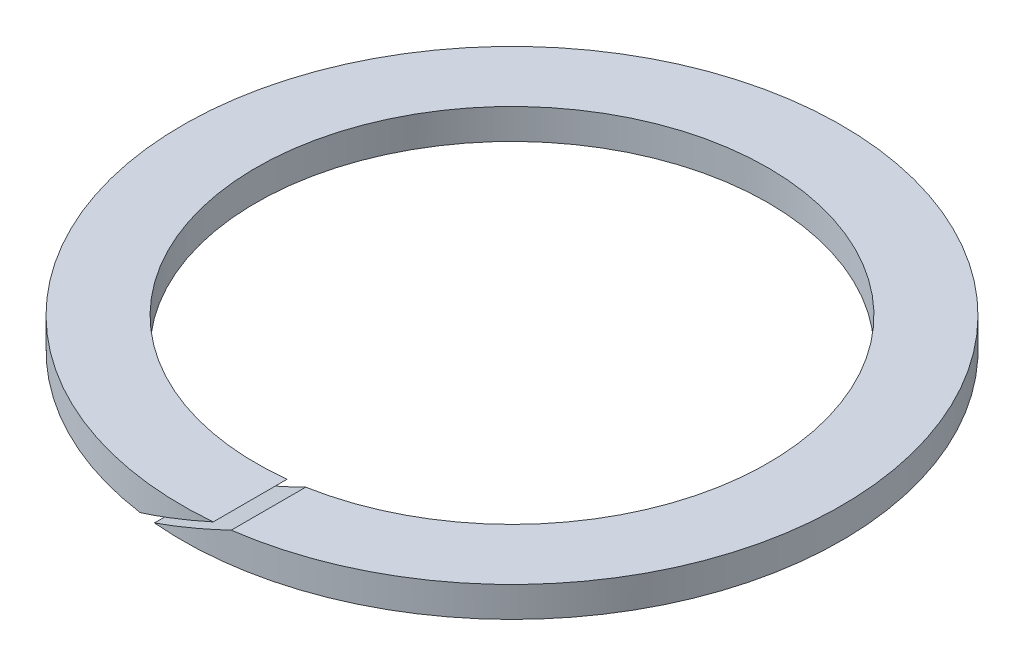
from build123d import *

# Parameters (mm, degrees)
SKETCH3_R                = 13.5382
SKETCH3_R_2              = 10.5156
BOSS_EXTRUDE1_DEPTH      = 0.6223
BOSS_EXTRUDE1_DEPTH_BACK = 0.6223
CUT_EXTRUDE1_DEPTH       = 14.5382


with BuildPart() as part:
    # Sketch3 → Boss-Extrude1 (new body, two sides)
    with BuildSketch(Plane(origin=(0, 0, 0), x_dir=(1, 0, 0), z_dir=(0, 1, 0))) as boss_extrude1_sk:
        Circle(SKETCH3_R)
        Circle(SKETCH3_R_2, mode=Mode.SUBTRACT)
    extrude(amount=BOSS_EXTRUDE1_DEPTH)
    extrude(boss_extrude1_sk.sketch, amount=-BOSS_EXTRUDE1_DEPTH_BACK)

    # Sketch4 → Cut-Extrude1 (cut, through all)
    with BuildSketch(Plane.XY):
        Polygon((2.838309027, 1.280985718), (-2.9315561, -1.050191113), (-2.838309027, -1.280985718), (2.9315561, 1.050191113), align=None)
    extrude(amount=CUT_EXTRUDE1_DEPTH, mode=Mode.SUBTRACT)


solid = part.part
